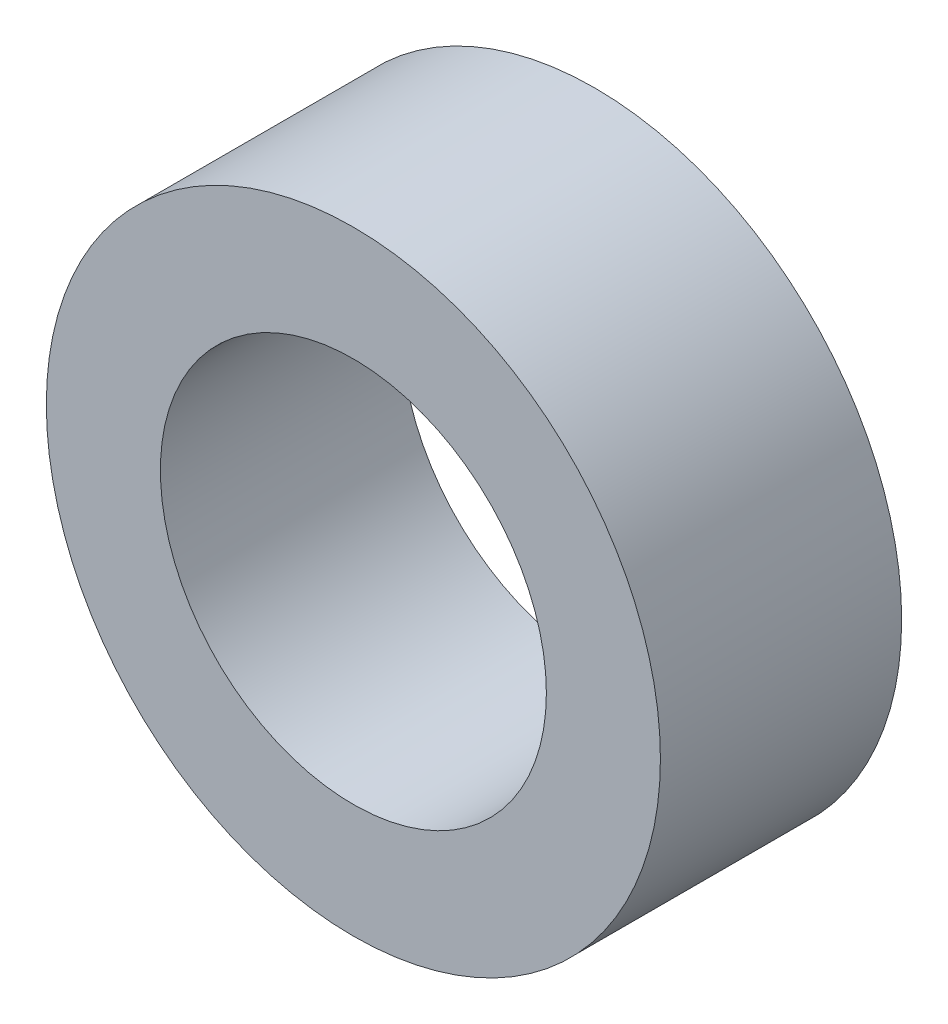
from build123d import *

# Parameters (mm, degrees)
SKETCH1_R           = 7
SKETCH1_R_2         = 4.4
BOSS_EXTRUDE1_DEPTH = 5.5


with BuildPart() as part:
    # Sketch1 → Boss-Extrude1 (new body)
    with BuildSketch(Plane.XY):
        Circle(SKETCH1_R)
        Circle(SKETCH1_R_2, mode=Mode.SUBTRACT)
    extrude(amount=BOSS_EXTRUDE1_DEPTH)


solid = part.part
